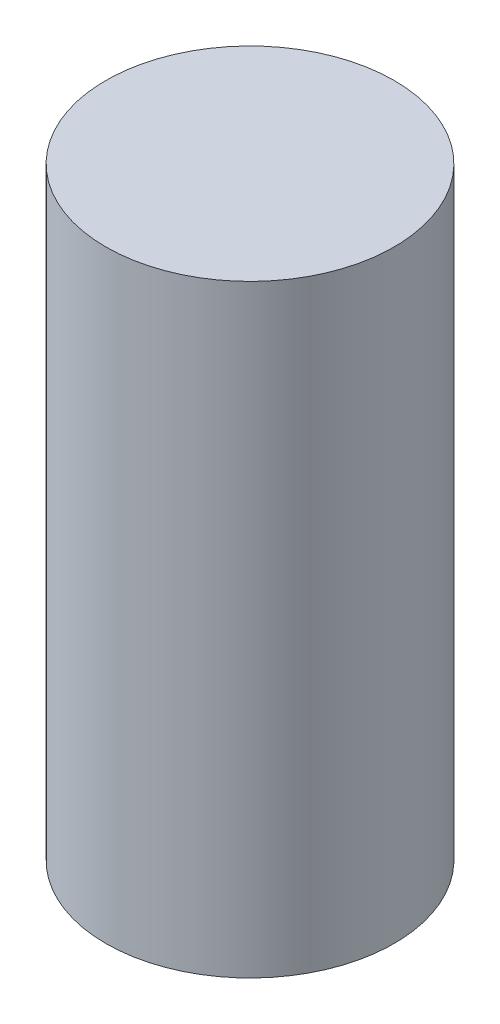
from build123d import *

# Parameters (mm, degrees)
SKETCH1_R           = 14.2875
BOSS_EXTRUDE1_DEPTH = 59.7803732


with BuildPart() as part:
    # Sketch1 → Boss-Extrude1 (new body)
    with BuildSketch(Plane(origin=(0, 0, 0), x_dir=(1, 0, 0), z_dir=(0, 1, 0))):
        Circle(SKETCH1_R)
    extrude(amount=BOSS_EXTRUDE1_DEPTH)


solid = part.part
